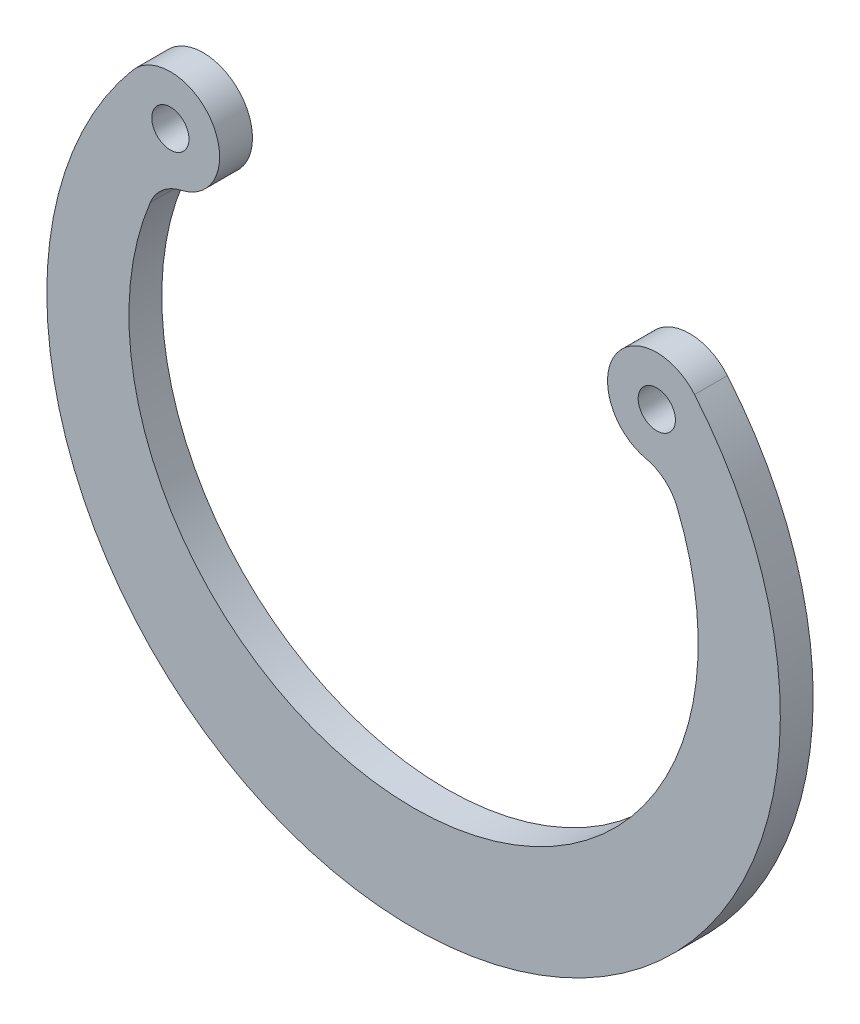
from build123d import *

# Parameters (mm, degrees)
SKETCH_1_R      = 0.85
EXTRUDE_1_DEPTH = 1.5


with BuildPart() as part:
    # Эскиз1 → Бобышка-Вытянуть1 (new body)
    with BuildSketch(Plane.XY):
        with BuildLine():
            ThreePointArc((-12.028004227, 5.932252459), (-11.46771854, 6.701660536), (-10.615237279, 7.124962483))
            ThreePointArc((-10.615237279, 7.124962483), (-9.185534057, 10.490032127), (-12.831244422, 10.766692462))
            ThreePointArc((-12.831244422, 10.766692462), (0, -16.75), (12.831244422, 10.766692462))
            ThreePointArc((12.831244422, 10.766692462), (9.185534057, 10.490032127), (10.615237279, 7.124962483))
            ThreePointArc((10.615237279, 7.124962483), (11.46771854, 6.701660536), (12.028004227, 5.932252459))
            ThreePointArc((12.028004227, 5.932252459), (0, -12), (-12.028004227, 5.932252459))
        make_face()
        with Locations((-11.107644425, 9.32042034)):
            Circle(SKETCH_1_R, mode=Mode.SUBTRACT)
        with Locations((11.107644425, 9.32042034)):
            Circle(SKETCH_1_R, mode=Mode.SUBTRACT)
    extrude(amount=-EXTRUDE_1_DEPTH)


solid = part.part
